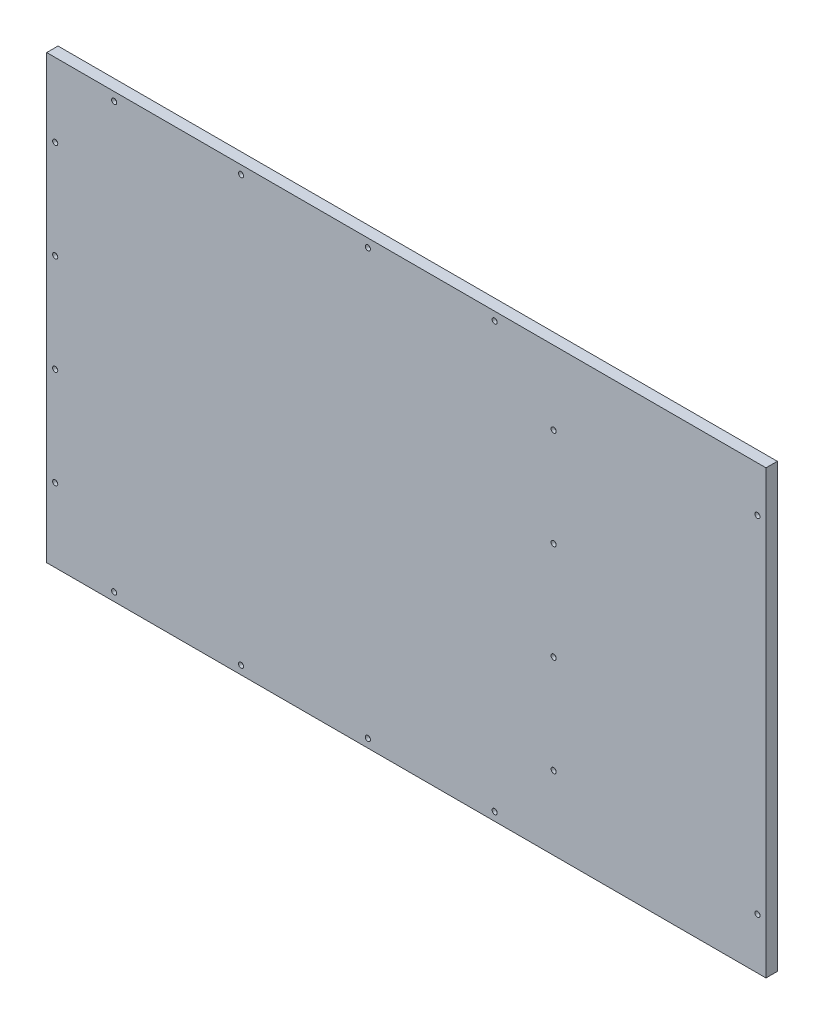
from build123d import *

# Parameters (mm, degrees)
SKETCH1_W                     = 806.6532
SKETCH1_H                     = 495.5032
BOSS_EXTRUDE1_DEPTH           = 12.7
SKETCH2_R                     = 2.8956
SIDEBARHOLEMASTER_DEPTH       = 13.7
SKETCH3_R                     = 6.35
COUNTERSINK_DEPTH             = 8.89
LPATTERN1_COUNT               = 4
LPATTERN1_PITCH               = 110.202133333
SKETCH4_R                     = 2.8956
REARFRONTBARMOUNT_DEPTH       = 13.7
SKETCH5_R                     = 6.35
REARFRONTBARCOUNTERSINK_DEPTH = 8.89
LPATTERN2_COUNT               = 4
LPATTERN2_PITCH               = 142.24
SKETCH6_R                     = 2.8956
EBFORWARDMOUNTHOLE_DEPTH      = 13.7
SKETCH7_R                     = 6.35
EB_MOUNTS_COUNTERSINKS_DEPTH  = 8.89


with BuildPart() as part:
    # Sketch1 → Boss-Extrude1 (new body)
    with BuildSketch(Plane.XY):
        Rectangle(SKETCH1_W, SKETCH1_H)
    extrude(amount=BOSS_EXTRUDE1_DEPTH)

    # Sketch2 → SideBarHoleMaster (cut, through all)
    with BuildSketch(Plane.XY.offset(12.7)):
        with Locations((-393.8016, -165.3032)):
            Circle(SKETCH2_R)
        with Locations((165.2016, -165.3032)):
            Circle(SKETCH2_R)
    sidebarholemaster = extrude(amount=-SIDEBARHOLEMASTER_DEPTH, mode=Mode.SUBTRACT)

    # Sketch3 → Countersink (cut)
    with BuildSketch(Plane(origin=(0, 0, 0), x_dir=(-1, 0, 0), z_dir=(0, 0, -1))):
        with Locations((-165.2016, -165.3032)):
            Circle(SKETCH3_R)
        with Locations((393.8016, -165.3032)):
            Circle(SKETCH3_R)
    countersink = extrude(amount=-COUNTERSINK_DEPTH, mode=Mode.SUBTRACT)

    # LPattern1: SideBarHoleMaster, Countersink ×4
    with Locations(*[(0, i * LPATTERN1_PITCH, 0) for i in range(1, LPATTERN1_COUNT)]):
        add(sidebarholemaster, mode=Mode.SUBTRACT)
        add(countersink, mode=Mode.SUBTRACT)

    # Sketch4 → RearFrontBarMount (cut, through all)
    with BuildSketch(Plane.XY.offset(12.7)):
        with Locations((-327.66, -238.2266)):
            Circle(SKETCH4_R)
        with Locations((-327.66, 238.2266)):
            Circle(SKETCH4_R)
    rearfrontbarmount = extrude(amount=-REARFRONTBARMOUNT_DEPTH, mode=Mode.SUBTRACT)

    # Sketch5 → RearFrontBarCounterSink (cut)
    with BuildSketch(Plane(origin=(0, 0, 0), x_dir=(-1, 0, 0), z_dir=(0, 0, -1))):
        with Locations((327.66, -238.2266)):
            Circle(SKETCH5_R)
        with Locations((327.66, 238.2266)):
            Circle(SKETCH5_R)
    rearfrontbarcountersink = extrude(amount=-REARFRONTBARCOUNTERSINK_DEPTH, mode=Mode.SUBTRACT)

    # LPattern2: RearFrontBarMount, RearFrontBarCounterSink ×4
    with Locations(*[(i * LPATTERN2_PITCH, 0, 0) for i in range(1, LPATTERN2_COUNT)]):
        add(rearfrontbarmount, mode=Mode.SUBTRACT)
        add(rearfrontbarcountersink, mode=Mode.SUBTRACT)

    # Sketch6 → EBForwardMountHole (cut, through all)
    with BuildSketch(Plane.XY.offset(12.7)):
        with Locations((393.8016, 196.7484)):
            Circle(SKETCH6_R)
        with Locations((393.8016, -190.6016)):
            Circle(SKETCH6_R)
    extrude(amount=-EBFORWARDMOUNTHOLE_DEPTH, mode=Mode.SUBTRACT)

    # Sketch7 → EB-Mounts-Countersinks (cut)
    with BuildSketch(Plane(origin=(0, 0, 0), x_dir=(-1, 0, 0), z_dir=(0, 0, -1))):
        with Locations((-393.8016, 196.7484)):
            Circle(SKETCH7_R)
        with Locations((-393.8016, -190.6016)):
            Circle(SKETCH7_R)
    extrude(amount=-EB_MOUNTS_COUNTERSINKS_DEPTH, mode=Mode.SUBTRACT)


solid = part.part
